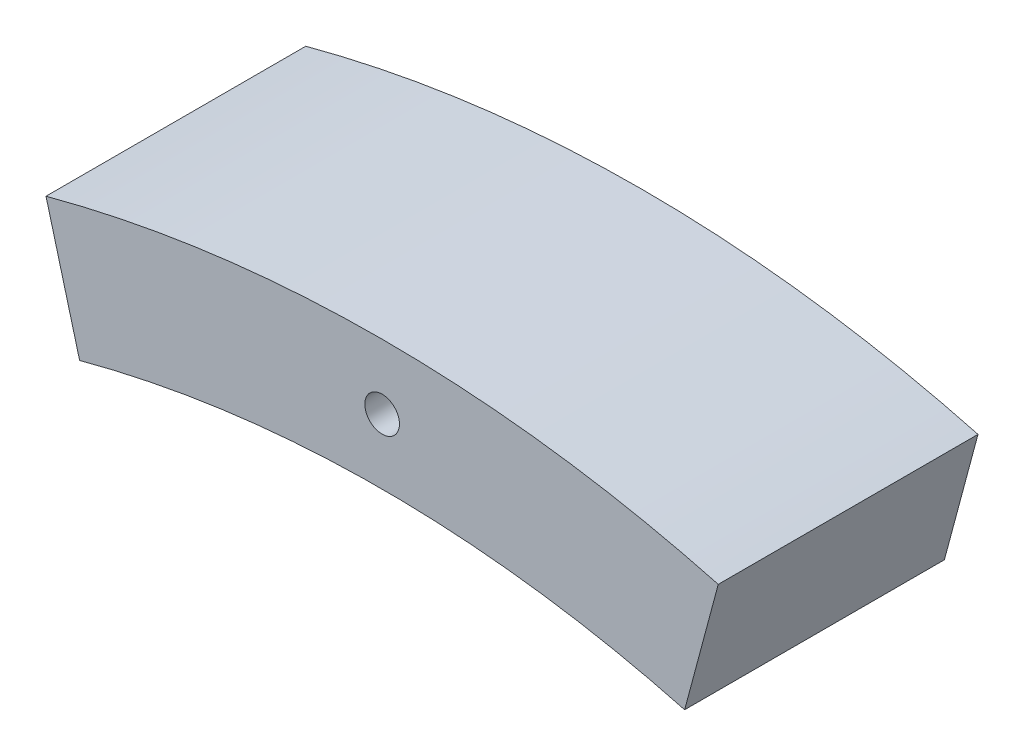
from build123d import *

# Parameters (mm, degrees)
BOSS_EXTRUDE1_DEPTH      = 15
BOSS_EXTRUDE1_DEPTH_BACK = 15
SKETCH1_R                = 2


with BuildPart() as part:
    # Sketch1 → Boss-Extrude1 (new, two sides: drawn at the far end of the back side and taken through both)
    with BuildSketch(Plane.XY.offset(-BOSS_EXTRUDE1_DEPTH_BACK)):
        with BuildLine():
            Line((-34.940571089, 130.399986549), (-38.822856765, 144.888873943))
            ThreePointArc((-38.822856765, 144.888873943), (0, 150), (38.822856765, 144.888873943))
            Line((38.822856765, 144.888873943), (34.940571089, 130.399986549))
            ThreePointArc((34.940571089, 130.399986549), (0, 135), (-34.940571089, 130.399986549))
        make_face()
        with Locations((0, 142.5)):
            Circle(SKETCH1_R, mode=Mode.SUBTRACT)
    extrude(amount=BOSS_EXTRUDE1_DEPTH + BOSS_EXTRUDE1_DEPTH_BACK)


solid = part.part
